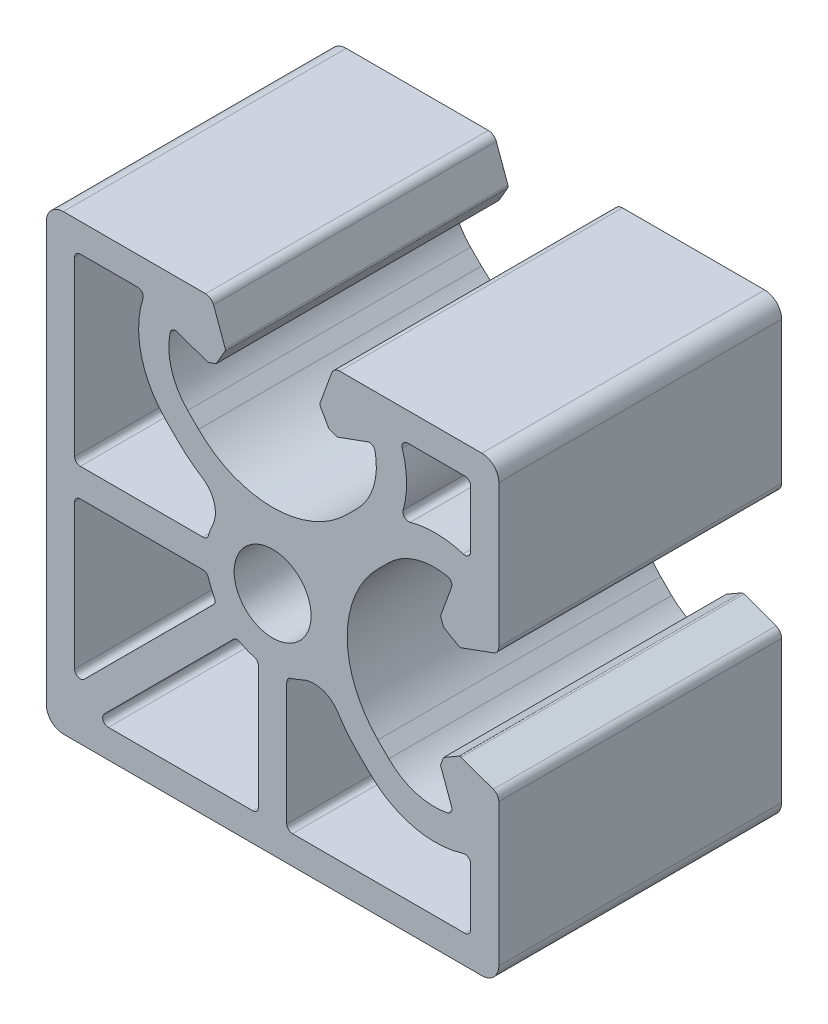
from build123d import *

# Parameters (mm, degrees)
SK_MAIN_EXTRUSION_R  = 3.4
MAIN_EXTRUSION_DEPTH = 25


with BuildPart() as part:
    # Sk Main Extrusion → Main Extrusion (new body)
    with BuildSketch(Plane.XY):
        with BuildLine():
            Line((16.671180212, 4.190076845), (19.506515107, 5.222054351))
            ThreePointArc((19.506515107, 5.222054351), (19.864364033, 5.496641489), (20, 5.926823816))
            Line((20, 5.926823816), (20, 18.5))
            ThreePointArc((20, 18.5), (19.560660172, 19.560660172), (18.5, 20))
            Line((18.5, 20), (5.926823816, 20))
            ThreePointArc((5.926823816, 20), (5.496641489, 19.864364033), (5.222054351, 19.506515107))
            Line((5.222054351, 19.506515107), (4.190076845, 16.671180212))
            ThreePointArc((4.190076845, 16.671180212), (4.175951325, 16.563886241), (4.208493649, 16.460675177))
            Line((4.208493649, 16.460675177), (4.987558066, 15.111296024))
            Line((4.987558066, 15.111296024), (5.718509166, 14.845251581))
            Line((5.718509166, 14.845251581), (8.396186179, 15.81984631))
            ThreePointArc((8.396186179, 15.81984631), (8.811074612, 15.786489799), (9.056960151, 15.450654467))
            ThreePointArc((9.056960151, 15.450654467), (8.933433013, 12.665882372), (7.504160339, 10.272684887))
            Line((7.504160339, 10.272684887), (6.540737726, 9.309262274))
            ThreePointArc((6.540737726, 9.309262274), (0, 6.6), (-6.540737726, 9.309262274))
            Line((-6.540737726, 9.309262274), (-7.504160339, 10.272684887))
            ThreePointArc((-7.504160339, 10.272684887), (-8.933433013, 12.665882372), (-9.056960151, 15.450654467))
            ThreePointArc((-9.056960151, 15.450654467), (-8.811074612, 15.786489799), (-8.396186179, 15.81984631))
            Line((-8.396186179, 15.81984631), (-5.718509166, 14.845251581))
            Line((-5.718509166, 14.845251581), (-4.987558066, 15.111296024))
            Line((-4.987558066, 15.111296024), (-4.208493649, 16.460675177))
            ThreePointArc((-4.208493649, 16.460675177), (-4.175951325, 16.563886241), (-4.190076845, 16.671180212))
            Line((-4.190076845, 16.671180212), (-5.222054351, 19.506515107))
            ThreePointArc((-5.222054351, 19.506515107), (-5.496641489, 19.864364033), (-5.926823816, 20))
            Line((-5.926823816, 20), (-18.5, 20))
            ThreePointArc((-18.5, 20), (-19.560660172, 19.560660172), (-20, 18.5))
            Line((-20, 18.5), (-20, -18.5))
            ThreePointArc((-20, -18.5), (-19.560660172, -19.560660172), (-18.5, -20))
            Line((-18.5, -20), (18.5, -20))
            ThreePointArc((18.5, -20), (19.560660172, -19.560660172), (20, -18.5))
            Line((20, -18.5), (20, -5.926823816))
            ThreePointArc((20, -5.926823816), (19.864364033, -5.496641489), (19.506515107, -5.222054351))
            Line((19.506515107, -5.222054351), (16.671180212, -4.190076845))
            ThreePointArc((16.671180212, -4.190076845), (16.563886241, -4.175951325), (16.460675177, -4.208493649))
            Line((16.460675177, -4.208493649), (15.111296024, -4.987558066))
            Line((15.111296024, -4.987558066), (14.845251581, -5.718509166))
            Line((14.845251581, -5.718509166), (15.81984631, -8.396186179))
            ThreePointArc((15.81984631, -8.396186179), (15.786489799, -8.811074612), (15.450654467, -9.056960151))
            ThreePointArc((15.450654467, -9.056960151), (12.665882372, -8.933433013), (10.272684887, -7.504160339))
            Line((10.272684887, -7.504160339), (9.309262274, -6.540737726))
            ThreePointArc((9.309262274, -6.540737726), (6.6, 0), (9.309262274, 6.540737726))
            Line((9.309262274, 6.540737726), (10.272684887, 7.504160339))
            ThreePointArc((10.272684887, 7.504160339), (12.665882372, 8.933433013), (15.450654467, 9.056960151))
            ThreePointArc((15.450654467, 9.056960151), (15.786489799, 8.811074612), (15.81984631, 8.396186179))
            Line((15.81984631, 8.396186179), (14.845251581, 5.718509166))
            Line((14.845251581, 5.718509166), (15.111296024, 4.987558066))
            Line((15.111296024, 4.987558066), (16.460675177, 4.208493649))
            ThreePointArc((16.460675177, 4.208493649), (16.563886241, 4.175951325), (16.671180212, 4.190076845))
        make_face()
        Circle(SK_MAIN_EXTRUSION_R, mode=Mode.SUBTRACT)
        with BuildLine():
            Line((-8.308504679, 7.441495321), (-9.444282589, 8.577273231))
            ThreePointArc((-9.444282589, 8.577273231), (-11.611987193, 12.430514315), (-11.464011904, 16.849169473))
            ThreePointArc((-11.464011904, 16.849169473), (-11.537349181, 17.295452819), (-11.940719521, 17.5))
            Line((-11.940719521, 17.5), (-17, 17.5))
            ThreePointArc((-17, 17.5), (-17.353553391, 17.353553391), (-17.5, 17))
            Line((-17.5, 17), (-17.5, 1.75))
            ThreePointArc((-17.5, 1.75), (-17.353553391, 1.396446609), (-17, 1.25))
            Line((-17, 1.25), (-6.156094541, 1.25))
            ThreePointArc((-6.156094541, 1.25), (-5.854730455, 1.351026708), (-5.675149655, 1.61328125))
            ThreePointArc((-5.675149655, 1.61328125), (-5.51245547, 2.10305366), (-5.307583096, 2.576734694))
            ThreePointArc((-5.307583096, 2.576734694), (-5.153883821, 4.359333373), (-6.230846881, 5.788120301))
            ThreePointArc((-6.230846881, 5.788120301), (-7.316529108, 6.555931161), (-8.308504679, 7.441495321))
        make_face(mode=Mode.SUBTRACT)
        with BuildLine():
            Line((17.5, 11.940719521), (17.5, 17))
            ThreePointArc((17.5, 17), (17.353553391, 17.353553391), (17, 17.5))
            Line((17, 17.5), (11.940719521, 17.5))
            ThreePointArc((11.940719521, 17.5), (11.537349181, 17.295452819), (11.464011904, 16.849169473))
            ThreePointArc((11.464011904, 16.849169473), (11.844928721, 14.508523804), (11.540116235, 12.156756572))
            ThreePointArc((11.540116235, 12.156756572), (11.66791097, 11.66791097), (12.156756572, 11.540116235))
            ThreePointArc((12.156756572, 11.540116235), (14.508523804, 11.844928721), (16.849169473, 11.464011904))
            ThreePointArc((16.849169473, 11.464011904), (17.295452819, 11.537349181), (17.5, 11.940719521))
        make_face(mode=Mode.SUBTRACT)
        with BuildLine():
            Line((-17.5, -1.75), (-17.5, -14.525126266))
            ThreePointArc((-17.5, -14.525126266), (-17.191341716, -14.987066032), (-16.646446609, -14.878679656))
            Line((-16.646446609, -14.878679656), (-5.236899672, -3.469132719))
            ThreePointArc((-5.236899672, -3.469132719), (-5.095239754, -3.18459946), (-5.153698917, -2.872174694))
            ThreePointArc((-5.153698917, -2.872174694), (-5.450889242, -2.257832251), (-5.675149655, -1.61328125))
            ThreePointArc((-5.675149655, -1.61328125), (-5.854730455, -1.351026708), (-6.156094541, -1.25))
            Line((-6.156094541, -1.25), (-17, -1.25))
            ThreePointArc((-17, -1.25), (-17.353553391, -1.396446609), (-17.5, -1.75))
        make_face(mode=Mode.SUBTRACT)
        with BuildLine():
            Line((-14.525126266, -17.5), (-1.75, -17.5))
            ThreePointArc((-1.75, -17.5), (-1.396446609, -17.353553391), (-1.25, -17))
            Line((-1.25, -17), (-1.25, -6.156094541))
            ThreePointArc((-1.25, -6.156094541), (-1.351026708, -5.854730455), (-1.61328125, -5.675149655))
            ThreePointArc((-1.61328125, -5.675149655), (-2.257832251, -5.450889242), (-2.872174694, -5.153698917))
            ThreePointArc((-2.872174694, -5.153698917), (-3.18459946, -5.095239754), (-3.469132719, -5.236899672))
            Line((-3.469132719, -5.236899672), (-14.878679656, -16.646446609))
            ThreePointArc((-14.878679656, -16.646446609), (-14.987066032, -17.191341716), (-14.525126266, -17.5))
        make_face(mode=Mode.SUBTRACT)
        with BuildLine():
            Line((1.75, -17.5), (17, -17.5))
            ThreePointArc((17, -17.5), (17.353553391, -17.353553391), (17.5, -17))
            Line((17.5, -17), (17.5, -11.940719521))
            ThreePointArc((17.5, -11.940719521), (17.295452819, -11.537349181), (16.849169473, -11.464011904))
            ThreePointArc((16.849169473, -11.464011904), (12.430514315, -11.611987193), (8.577273231, -9.444282589))
            Line((8.577273231, -9.444282589), (7.441495321, -8.308504679))
            ThreePointArc((7.441495321, -8.308504679), (6.555931161, -7.316529108), (5.788120301, -6.230846881))
            ThreePointArc((5.788120301, -6.230846881), (4.359333373, -5.153883821), (2.576734694, -5.307583096))
            ThreePointArc((2.576734694, -5.307583096), (2.10305366, -5.51245547), (1.61328125, -5.675149655))
            ThreePointArc((1.61328125, -5.675149655), (1.351026708, -5.854730455), (1.25, -6.156094541))
            Line((1.25, -6.156094541), (1.25, -17))
            ThreePointArc((1.25, -17), (1.396446609, -17.353553391), (1.75, -17.5))
        make_face(mode=Mode.SUBTRACT)
    extrude(amount=-MAIN_EXTRUSION_DEPTH)


solid = part.part
